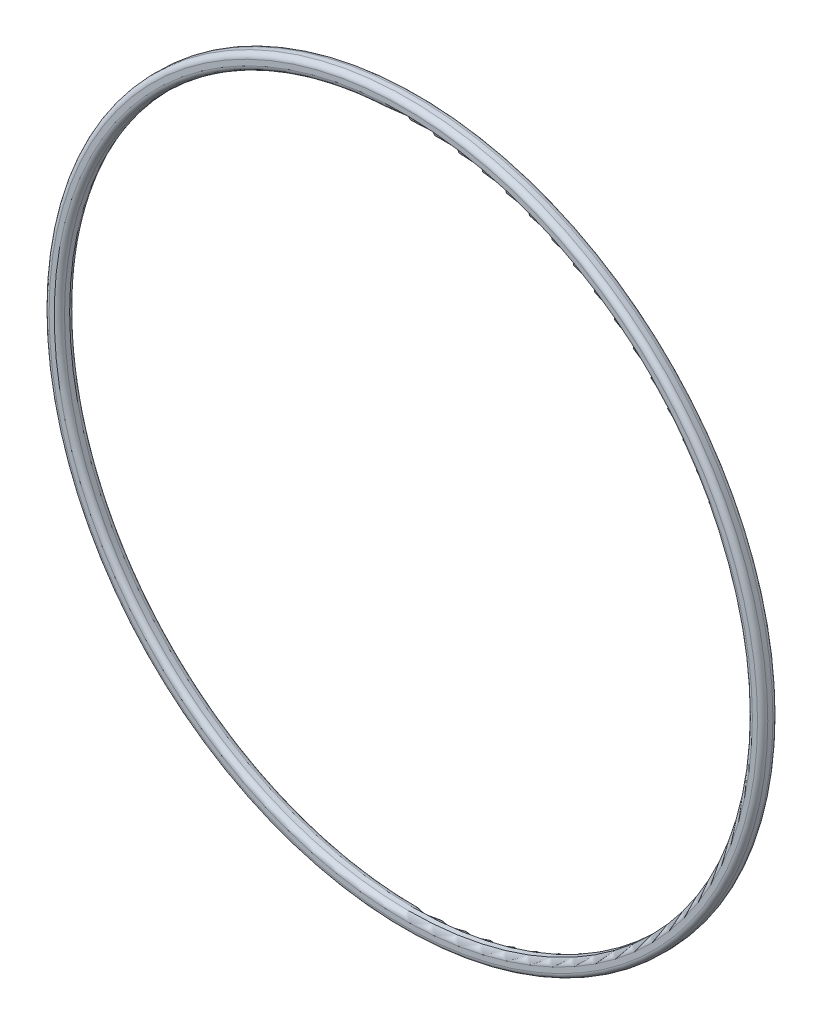
from build123d import *

# Parameters (mm, degrees)
SCHIZZO1_R                   = 70
SCHIZZO1_R_2                 = 67
ESTRUSIONE_ESTRUSIONE1_DEPTH = 3
RACCORDO1_R                  = 1


with BuildPart() as part:
    # Schizzo1 → Estrusione-Estrusione1 (new body)
    with BuildSketch(Plane.XY):
        Circle(SCHIZZO1_R)
        Circle(SCHIZZO1_R_2, mode=Mode.SUBTRACT)
    extrude(amount=ESTRUSIONE_ESTRUSIONE1_DEPTH)

    # Raccordo1
    raccordo1_edges = [part.edges().sort_by_distance(p)[0] for p in [
        (-70, 0, 0),
        (-70, 0, 3),
        (-67, 0, 0),
        (-67, 0, 3),
    ]]
    fillet(raccordo1_edges, radius=RACCORDO1_R)


solid = part.part
